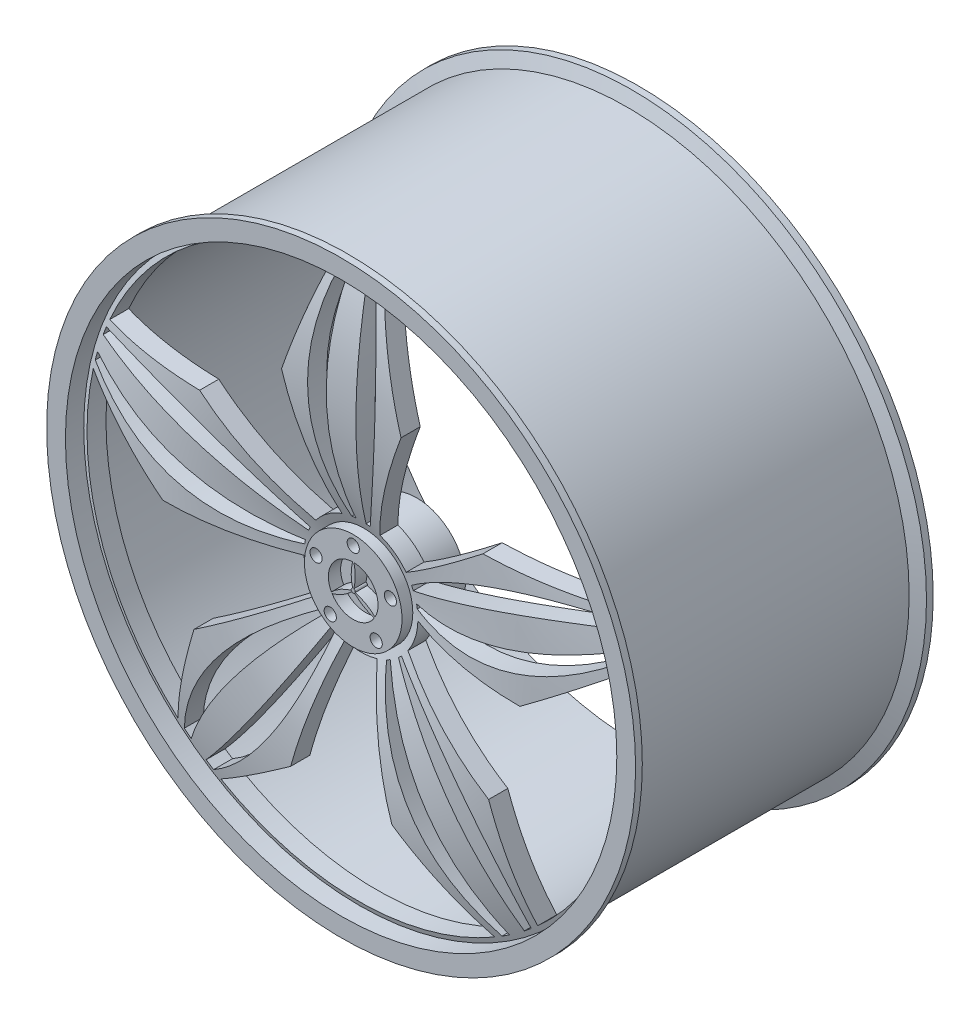
from build123d import *

# Parameters (mm, degrees)
SKETCH5_R           = 40
BOSS_EXTRUDE1_DEPTH = 52
SKETCH9_R           = 5
CUT_EXTRUDE1_DEPTH  = 102
CUT_EXTRUDE2_DEPTH  = 448
CUT_EXTRUDE3_DEPTH  = 10


with BuildPart() as part:
    # Sketch2 → Revolve1 (revolve)
    with BuildSketch(Plane(origin=(0, 0, 0), x_dir=(0, 0, -1), z_dir=(1, 0, 0))):
        Polygon((112.718637456, 230.78728464), (-112.718637456, 230.78728464), (-116.422002707, 241.3), (-121.92, 241.3), (-121.92, 225.9), (121.92, 225.9), (121.92, 241.3), (116.422002707, 241.3), align=None)
    revolve(axis=Axis((0, 0, 133.504666922), (0, 0, -1)))



with BuildPart() as body_2:
    # Sketch5 → Boss-Extrude1 (new body)
    with BuildSketch(Plane.XY.offset(60)):
        Circle(SKETCH5_R)
    extrude(amount=BOSS_EXTRUDE1_DEPTH)


with BuildPart() as part_1:
    add(part.part)

    add(body_2.part)  # Revolve2 merges body 2
    # Sketch6 → Revolve2 (revolve)
    with BuildSketch(Plane(origin=(0, 0, 0), x_dir=(0, 0, -1), z_dir=(1, 0, 0))):
        with BuildLine():
            Line((-106.202712072, 227.958651849), (-90.71457886, 227.958651849))
            add(Edge.make_bspline(
                [(-87.559588761, 36.989816723), (-123.201321452, 132.273729861), (-90.71457886, 227.958651849)],
                knots=[0, 0, 0, 1, 1, 1], degree=2))
            Line((-87.559588761, 36.989816723), (-102.000162167, 36.989816723))
            add(Edge.make_bspline(
                [(-102.000162167, 36.989816723), (-139.614300653, 132.092726613), (-106.202712072, 227.958651849)],
                knots=[0, 0, 0, 1, 1, 1], degree=2))
        make_face()
    revolve(axis=Axis((0, 0, 133.504666922), (0, 0, -1)))

    # Sketch9 → Cut-Extrude1 (cut)
    with BuildSketch(Plane.XY.offset(112)):
        with Locations((0, 32.020469859)):
            Circle(SKETCH9_R)
        with Locations((30.453276515, 9.894869354)):
            Circle(SKETCH9_R)
        with Locations((18.821159955, -25.905104284)):
            Circle(SKETCH9_R)
        with Locations((-18.821159955, -25.905104284)):
            Circle(SKETCH9_R)
        with Locations((-30.453276515, 9.894869354)):
            Circle(SKETCH9_R)
    extrude(amount=-CUT_EXTRUDE1_DEPTH, mode=Mode.SUBTRACT)

    # Sketch10 → Cut-Extrude2 (cut)
    with BuildSketch(Plane.XY.offset(130)):
        with BuildLine():
            Line((116.071499082, 89.196027831), (203.281436639, 88.953159102))
            ThreePointArc((203.281436639, 88.953159102), (130.424775444, 179.514302903), (21.782063046, 220.820172823))
            Line((21.782063046, 220.820172823), (48.962397718, 137.953643989))
            Line((48.962397718, 137.953643989), (15.606589408, 43.972231334))
            ThreePointArc((15.606589408, 43.972231334), (27.425853035, 37.74844827), (36.997375795, 28.430915317))
            Line((36.997375795, 28.430915317), (116.071499082, 89.196027831))
        make_face()
        with BuildLine():
            Line((-15.606589408, 43.972231334), (-48.962397718, 137.953643989))
            Line((-48.962397718, 137.953643989), (-21.782063046, 220.820172823))
            ThreePointArc((-21.782063046, 220.820172823), (-130.424775444, 179.514302903), (-203.281436639, 88.953159102))
            Line((-203.281436639, 88.953159102), (-116.071499082, 89.196027831))
            Line((-116.071499082, 89.196027831), (-36.997375795, 28.430915317))
            ThreePointArc((-36.997375795, 28.430915317), (-27.425853035, 37.74844827), (-15.606589408, 43.972231334))
        make_face()
        with BuildLine():
            Line((46.642778498, -1.254581791), (146.331925042, -3.935986974))
            Line((146.331925042, -3.935986974), (216.743491947, 47.521213105))
            ThreePointArc((216.743491947, 47.521213105), (211.031719643, -68.568362242), (147.416900171, -165.844097092))
            Line((147.416900171, -165.844097092), (120.698529276, -82.827467128))
            Line((120.698529276, -82.827467128), (38.472225144, -26.400959337))
            ThreePointArc((38.472225144, -26.400959337), (44.37596238, -14.418624217), (46.642778498, -1.254581791))
        make_face()
        with BuildLine():
            Line((13.220233033, -44.747605523), (41.475705598, -140.386217718))
            Line((41.475705598, -140.386217718), (112.172781817, -191.450447938))
            ThreePointArc((112.172781817, -191.450447938), (0, -221.891881321), (-112.172781817, -191.450447938))
            Line((-112.172781817, -191.450447938), (-41.475705598, -140.386217718))
            Line((-41.475705598, -140.386217718), (-13.220233033, -44.747605523))
            ThreePointArc((-13.220233033, -44.747605523), (0, -46.659648107), (13.220233033, -44.747605523))
        make_face()
        with BuildLine():
            Line((-38.472225144, -26.400959337), (-120.698529276, -82.827467128))
            Line((-120.698529276, -82.827467128), (-147.416900171, -165.844097092))
            ThreePointArc((-147.416900171, -165.844097092), (-211.031719643, -68.568362242), (-216.743491947, 47.521213104))
            Line((-216.743491947, 47.521213104), (-146.331925042, -3.935986974))
            Line((-146.331925042, -3.935986974), (-46.642778498, -1.254581791))
            ThreePointArc((-46.642778498, -1.254581791), (-44.37596238, -14.418624217), (-38.472225144, -26.400959337))
        make_face()
        with BuildLine():
            ThreePointArc((-7.539821502, 221.763743854), (-11.172749284, 221.610416429), (-14.802676774, 221.397578479))
            add(Edge.make_bspline(
                [(-7.539821502, 46.046431493), (-43.619453518, 132.702951288), (-14.802676774, 221.397578479)],
                knots=[0, 0, 0, 1, 1, 1], degree=2))
            ThreePointArc((-7.539821502, 46.046431493), (-5.857562258, 46.290514427), (-4.167528601, 46.473158563))
            add(Edge.make_bspline(
                [(-4.167528601, 46.473158563), (-18.319961725, 133.918435742), (-7.539821502, 221.763743854)],
                knots=[0, 0, 0, 1, 1, 1], degree=2))
        make_face()
        with BuildLine():
            ThreePointArc((14.802676774, 221.397578479), (11.172749284, 221.610416429), (7.539821502, 221.763743854))
            add(Edge.make_bspline(
                [(4.167528601, 46.473158563), (18.319961725, 133.918435742), (7.539821502, 221.763743854)],
                knots=[0, 0, 0, 1, 1, 1], degree=2))
            ThreePointArc((4.167528601, 46.473158563), (5.857562258, 46.290514427), (7.539821502, 46.046431493))
            add(Edge.make_bspline(
                [(7.539821502, 46.046431493), (43.619453518, 132.702951288), (14.802676774, 221.397578479)],
                knots=[0, 0, 0, 1, 1, 1], degree=2))
        make_face()
        with BuildLine():
            ThreePointArc((42.910763122, 18.324551011), (42.214809105, 19.875428391), (41.462825745, 21.399926232))
            add(Edge.make_bspline(
                [(41.462825745, 21.399926232), (112.728854132, 82.492032657), (205.987331019, 82.493796468)],
                knots=[0, 0, 0, 1, 1, 1], degree=2))
            ThreePointArc((205.987331019, 82.493796468), (207.311461221, 79.107300819), (208.579920691, 75.699561958))
            add(Edge.make_bspline(
                [(42.910763122, 18.324551011), (121.702821455, 58.806391482), (208.579920691, 75.699561958)],
                knots=[0, 0, 0, 1, 1, 1], degree=2))
        make_face()
        with BuildLine():
            ThreePointArc((46.122691702, 7.058333491), (45.834981671, 8.733682881), (45.486437447, 10.397440546))
            add(Edge.make_bspline(
                [(45.486437447, 10.397440546), (133.025180474, 23.959753527), (213.239786649, 61.357969216)],
                knots=[0, 0, 0, 1, 1, 1], degree=2))
            ThreePointArc((213.239786649, 61.357969216), (214.216600026, 57.855468795), (215.13588839, 54.337432059))
            add(Edge.make_bspline(
                [(46.122691702, 7.058333491), (139.687158976, -0.477098353), (215.13588839, 54.337432059)],
                knots=[0, 0, 0, 1, 1, 1], degree=2))
        make_face()
        with BuildLine():
            ThreePointArc((30.687838694, -35.14796321), (31.947749113, -34.00682414), (33.165257082, -32.820549724))
            add(Edge.make_bspline(
                [(33.165257082, -32.820549724), (113.289716884, -81.720071305), (142.109848596, -170.413608401)],
                knots=[0, 0, 0, 1, 1, 1], degree=2))
            ThreePointArc((142.109848596, -170.413608401), (139.298278576, -172.719415764), (136.44930186, -174.97884163))
            add(Edge.make_bspline(
                [(30.687838694, -35.14796321), (93.536441911, -97.574087051), (136.44930186, -174.97884163)],
                knots=[0, 0, 0, 1, 1, 1], degree=2))
        make_face()
        with BuildLine():
            ThreePointArc((20.965569623, -41.684141492), (22.470014289, -40.892801559), (23.944635768, -40.04718691))
            add(Edge.make_bspline(
                [(23.944635768, -40.04718691), (63.894121167, -119.1104937), (124.249614401, -183.842433397)],
                knots=[0, 0, 0, 1, 1, 1], degree=2))
            ThreePointArc((124.249614401, -183.842433397), (121.220390486, -185.853770278), (118.158614451, -187.815198605))
            add(Edge.make_bspline(
                [(20.965569623, -41.684141492), (42.711958522, -132.997814286), (118.158614451, -187.815198605)],
                knots=[0, 0, 0, 1, 1, 1], degree=2))
        make_face()
        with BuildLine():
            ThreePointArc((-23.944635768, -40.04718691), (-22.470014289, -40.892801559), (-20.965569623, -41.684141492))
            add(Edge.make_bspline(
                [(-20.965569623, -41.684141492), (-42.711958522, -132.997814286), (-118.158614451, -187.815198605)],
                knots=[0, 0, 0, 1, 1, 1], degree=2))
            ThreePointArc((-118.158614451, -187.815198605), (-121.220390486, -185.853770278), (-124.249614401, -183.842433397))
            add(Edge.make_bspline(
                [(-23.944635768, -40.04718691), (-63.894121167, -119.1104937), (-124.249614401, -183.842433397)],
                knots=[0, 0, 0, 1, 1, 1], degree=2))
        make_face()
        with BuildLine():
            ThreePointArc((-33.165257082, -32.820549724), (-31.947749113, -34.00682414), (-30.687838694, -35.14796321))
            add(Edge.make_bspline(
                [(-30.687838694, -35.14796321), (-93.536441911, -97.574087051), (-136.44930186, -174.97884163)],
                knots=[0, 0, 0, 1, 1, 1], degree=2))
            ThreePointArc((-136.44930186, -174.97884163), (-139.298278576, -172.719415764), (-142.109848596, -170.413608401))
            add(Edge.make_bspline(
                [(-33.165257082, -32.820549724), (-113.289716884, -81.720071305), (-142.109848596, -170.413608401)],
                knots=[0, 0, 0, 1, 1, 1], degree=2))
        make_face()
        with BuildLine():
            ThreePointArc((-45.486437447, 10.397440546), (-45.834981671, 8.733682881), (-46.122691702, 7.058333491))
            add(Edge.make_bspline(
                [(-46.122691702, 7.058333491), (-139.687158976, -0.477098353), (-215.13588839, 54.337432059)],
                knots=[0, 0, 0, 1, 1, 1], degree=2))
            ThreePointArc((-215.13588839, 54.337432059), (-214.216600026, 57.855468795), (-213.239786649, 61.357969216))
            add(Edge.make_bspline(
                [(-45.486437447, 10.397440546), (-133.025180474, 23.959753527), (-213.239786649, 61.357969216)],
                knots=[0, 0, 0, 1, 1, 1], degree=2))
        make_face()
        with BuildLine():
            ThreePointArc((-41.462825745, 21.399926232), (-42.214809105, 19.875428391), (-42.910763122, 18.324551011))
            add(Edge.make_bspline(
                [(-42.910763122, 18.324551011), (-121.702821455, 58.806391482), (-208.579920691, 75.699561958)],
                knots=[0, 0, 0, 1, 1, 1], degree=2))
            ThreePointArc((-208.579920691, 75.699561958), (-207.311461221, 79.107300819), (-205.987331019, 82.493796468))
            add(Edge.make_bspline(
                [(-41.462825745, 21.399926232), (-112.728854132, 82.492032657), (-205.987331019, 82.493796468)],
                knots=[0, 0, 0, 1, 1, 1], degree=2))
        make_face()
    extrude(amount=-CUT_EXTRUDE2_DEPTH, mode=Mode.SUBTRACT)

    # Sketch11 → Cut-Extrude3 (cut)
    with BuildSketch(Plane.XY.offset(112)):
        with BuildLine():
            add(Edge.make_bspline(
                [(-0.450162146, 1.59584923), (-2.859273607, 10.939395131), (-0.487618552, 20.331048567)],
                knots=[0, 0, 0, 1, 1, 1], degree=2))
            ThreePointArc((-0.487618552, 20.331048567), (-17.606355246, 10.178681774), (-17.86232688, -9.722478394))
            add(Edge.make_bspline(
                [(-1.607127046, -0.408072761), (-10.895747242, -3.001148081), (-17.86232688, -9.722478394)],
                knots=[0, 0, 0, 1, 1, 1], degree=2))
            ThreePointArc((-1.607127046, -0.408072761), (-1.435978949, 0.829062833), (-0.450162146, 1.59584923))
        make_face()
        with BuildLine():
            add(Edge.make_bspline(
                [(0.450162146, 1.59584923), (2.848803142, 10.936567946), (0.511250163, 20.330468046)],
                knots=[0, 0, 0, 1, 1, 1], degree=2))
            ThreePointArc((0.450162146, 1.59584923), (1.322082851, 1.000738556), (1.658125665, 0))
            ThreePointArc((1.658125665, 0), (1.645326613, -0.205623587), (1.607127046, -0.408072761))
            add(Edge.make_bspline(
                [(1.607127046, -0.408072761), (10.903430889, -2.993493985), (17.851013821, -9.74323423)],
                knots=[0, 0, 0, 1, 1, 1], degree=2))
            ThreePointArc((17.851013821, -9.74323423), (17.618174616, 10.158210024), (0.511250163, 20.330468046))
        make_face()
        with BuildLine():
            ThreePointArc((1.156964901, -1.187776469), (0, -1.658125665), (-1.156964901, -1.187776469))
            add(Edge.make_bspline(
                [(-1.156964901, -1.187776469), (-8.044157282, -7.945901146), (-17.363395268, -10.587814337)],
                knots=[0, 0, 0, 1, 1, 1], degree=2))
            ThreePointArc((-17.363395268, -10.587814337), (-0.01181937, -20.336891798), (17.351076717, -10.607989652))
            add(Edge.make_bspline(
                [(1.156964901, -1.187776469), (8.0469441, -7.935419865), (17.351076717, -10.607989652)],
                knots=[0, 0, 0, 1, 1, 1], degree=2))
        make_face()
    extrude(amount=-CUT_EXTRUDE3_DEPTH, mode=Mode.SUBTRACT)


solid = part_1.part
